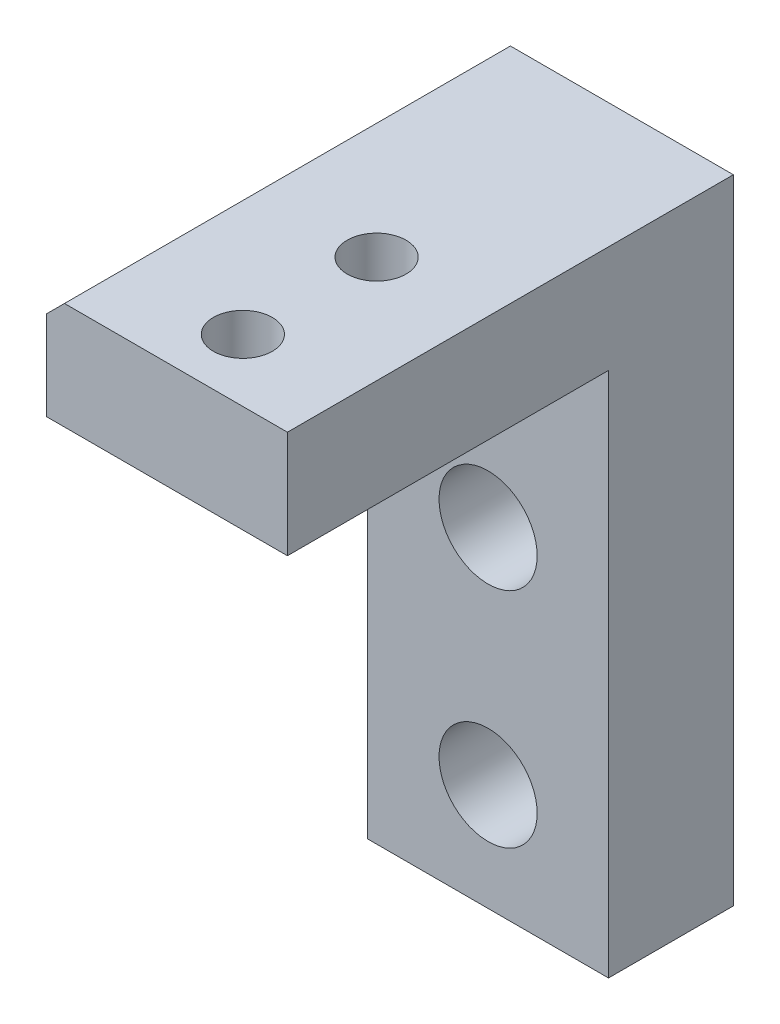
from build123d import *

# Parameters (mm, degrees)
SKETCH1_W             = 13.5
SKETCH1_H             = 35.5
SKETCH1_R             = 2.75
BOSS_EXTRUDE1_DEPTH   = 7
SKETCH2_W             = 13.5
SKETCH2_H             = 6
BOSS_EXTRUDE2_DEPTH   = 18
CHAMFER1_SIZE         = 1
M4X0_7_TAPPED_HOLE1_D = 3.3


with BuildPart() as part:
    # Sketch1 → Boss-Extrude1 (new body)
    with BuildSketch(Plane.XY):
        with Locations((-10.919683258, -1.606334842)):
            Rectangle(SKETCH1_W, SKETCH1_H)
        with Locations((-10.919683258, -13.356334842)):
            Circle(SKETCH1_R, mode=Mode.SUBTRACT)
        with Locations((-10.919683258, -0.856334842)):
            Circle(SKETCH1_R, mode=Mode.SUBTRACT)
    extrude(amount=BOSS_EXTRUDE1_DEPTH)

    # Sketch2 → Boss-Extrude2 (add)
    with BuildSketch(Plane.XY.offset(7)):
        with Locations((-10.919683258, 13.143665158)):
            Rectangle(SKETCH2_W, SKETCH2_H)
    extrude(amount=BOSS_EXTRUDE2_DEPTH)

    # Chamfer1
    chamfer1_edges = [part.edges().sort_by_distance(p)[0] for p in [
        (-17.669683258, 16.143665158, 12.5),
    ]]
    chamfer(chamfer1_edges, length=CHAMFER1_SIZE)

    # M4x0.7 Tapped Hole1 (through all)
    with Locations(Plane(origin=(0, 16.143665158, 0), x_dir=(1, 0, 0), z_dir=(0, 1, 0))):
        with Locations((-10.169683258, -21.5), (-10.169683258, -14)):
            Hole(M4X0_7_TAPPED_HOLE1_D / 2)


solid = part.part
